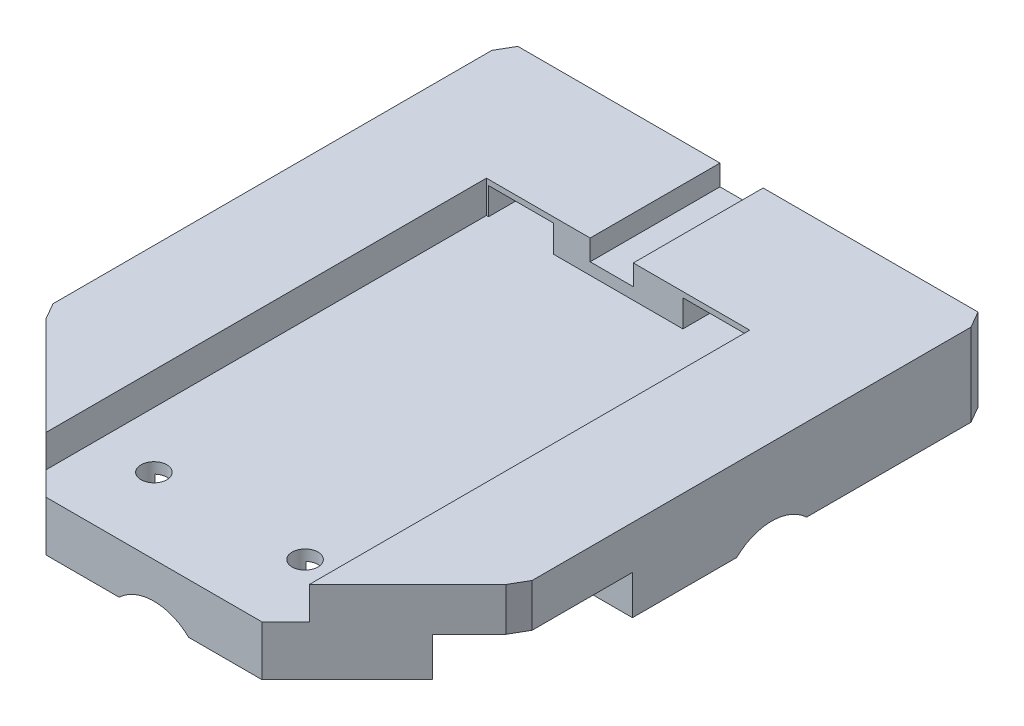
from build123d import *

# Parameters (mm, degrees)
BOSS_EXTRUDE1_DEPTH  = 3.81
SKETCH2_W            = 30.48
SKETCH2_H            = 48.26
CUT_EXTRUDE1_DEPTH   = 3.81
SKETCH4_W            = 30.48
SKETCH4_H            = 3.81
CUT_EXTRUDE2_DEPTH   = 27.94
SKETCH5_W            = 0.25
SKETCH5_H            = 3.81
CUT_EXTRUDE3_DEPTH   = 53.07
CUT_EXTRUDE4_DEPTH   = 7.874
BOSS_EXTRUDE2_DEPTH  = 1.27
SKETCH8_R            = 1.524
CUT_EXTRUDE6_DEPTH   = 6.08
SKETCH9_W            = 5.08
SKETCH9_H            = 5.08
CUT_EXTRUDE7_DEPTH   = 70.883682204
SKETCH10_OUTSIDE_W   = 96.904
SKETCH10_OUTSIDE_H   = 92.332
SKETCH10_OUTSIDE_W_2 = 56.38
SKETCH10_OUTSIDE_H_2 = 76.267364408
CUT_EXTRUDE8_DEPTH   = 6.08
SKETCH11_W           = 26.4
SKETCH11_H           = 2.57
SKETCH11_W_2         = 2.57
SKETCH11_H_2         = 26.4
BOSS_EXTRUDE4_DEPTH  = 4.62
SKETCH12_R           = 5.92
CUT_EXTRUDE9_DEPTH   = 57.38
SKETCH13_R           = 5.92
CUT_EXTRUDE10_DEPTH  = 70.883682204


with BuildPart() as part:
    # Sketch1 → Boss-Extrude1 (new body)
    with BuildSketch(Plane.XZ.offset(12.45)):
        Polygon((-12.7, 31.75), (12.7, 31.75), (27.068409794, 17.381590206), (37.228409794, -0.216045999), (37.228409794, -20.536045999), (27.068409794, -38.133682204), (-27.068409794, -38.133682204), (-37.228409794, -20.536045999), (-37.228409794, -0.216045999), (-27.068409794, 17.381590206), align=None)
    extrude(amount=-BOSS_EXTRUDE1_DEPTH)

    # Sketch2 → Cut-Extrude1 (cut)
    with BuildSketch(Plane.XZ.offset(12.45)):
        with Locations((0, 1.27)):
            Rectangle(SKETCH2_W, SKETCH2_H)
    extrude(amount=-CUT_EXTRUDE1_DEPTH, mode=Mode.SUBTRACT)

    # Sketch4 → Cut-Extrude2 (cut)
    with BuildSketch(Plane(origin=(0, 0, 25.4), x_dir=(-1, 0, 0), z_dir=(0, 0, -1))):
        with Locations((0, -10.545)):
            Rectangle(SKETCH4_W, SKETCH4_H)
    extrude(amount=-CUT_EXTRUDE2_DEPTH, mode=Mode.SUBTRACT)

    # Sketch5 → Cut-Extrude3 (cut, through all)
    with BuildSketch(Plane.XY.offset(-22.86)):
        with Locations((-15.365, -10.545)):
            Rectangle(SKETCH5_W, SKETCH5_H)
        with Locations((15.365, -10.545)):
            Rectangle(SKETCH5_W, SKETCH5_H)
    extrude(amount=CUT_EXTRUDE3_DEPTH, mode=Mode.SUBTRACT)

    # Sketch6 → Cut-Extrude4 (cut)
    with BuildSketch(Plane.XY.offset(-22.86)):
        Polygon((7.62, -12.45), (15.24, -12.45), (15.24, -9.275), (11.557, -9.275), (7.62, -9.275), align=None)
        Polygon((-15.24, -12.45), (-15.24, -9.275), (-11.557, -9.275), (-7.62, -9.275), (-7.62, -12.45), align=None)
    extrude(amount=-CUT_EXTRUDE4_DEPTH, mode=Mode.SUBTRACT)

    # Sketch1_3 → Boss-Extrude2 (add)
    with BuildSketch(Plane.XZ.offset(12.45)):
        Polygon((-12.7, 31.75), (12.7, 31.75), (27.068409794, 17.381590206), (37.228409794, -0.216045999), (37.228409794, -20.536045999), (27.068409794, -38.133682204), (-27.068409794, -38.133682204), (-37.228409794, -20.536045999), (-37.228409794, -0.216045999), (-27.068409794, 17.381590206), align=None)
    extrude(amount=BOSS_EXTRUDE2_DEPTH)

    # Sketch8 → Cut-Extrude6 (cut, through all)
    with BuildSketch(Plane.XZ.offset(13.72)):
        with Locations((-8.89, 22.86)):
            Circle(SKETCH8_R)
        with Locations((8.89, 22.86)):
            Circle(SKETCH8_R)
    extrude(amount=-CUT_EXTRUDE6_DEPTH, mode=Mode.SUBTRACT)

    # Sketch9 → Cut-Extrude7 (cut, through all)
    with BuildSketch(Plane(origin=(0, 0, -38.133682204), x_dir=(-1, 0, 0), z_dir=(0, 0, -1))):
        with Locations((0.7493, -8.5252)):
            Rectangle(SKETCH9_W, SKETCH9_H)
    extrude(amount=-CUT_EXTRUDE7_DEPTH, mode=Mode.SUBTRACT)

    # Sketch10 outside → Cut-Extrude8 (cut, through all)
    with BuildSketch(Plane.XZ.offset(13.72)):
        with Locations((0, -3.192)):
            Rectangle(SKETCH10_OUTSIDE_W, SKETCH10_OUTSIDE_H)
        Rectangle(SKETCH10_OUTSIDE_W_2, SKETCH10_OUTSIDE_H_2, mode=Mode.SUBTRACT)
    extrude(amount=-CUT_EXTRUDE8_DEPTH, mode=Mode.SUBTRACT)

    # Sketch11 → Boss-Extrude4 (add)
    with BuildSketch(Plane.XZ.offset(13.72)):
        with BuildLine():
            Line((22.725, 21.725), (12.7, 31.75))
            Line((12.7, 31.75), (-12.7, 31.75))
            Line((-12.7, 31.75), (-22.725, 21.725))
            Line((-22.725, 21.725), (-9.907030481, 21.725))
            ThreePointArc((-9.907030481, 21.725), (-9.511539036, 24.251497476), (-7.366, 22.86))
            ThreePointArc((-7.366, 22.86), (-7.498502524, 22.238460964), (-7.872969519, 21.725))
            Line((-7.872969519, 21.725), (7.872969519, 21.725))
            ThreePointArc((7.872969519, 21.725), (8.268460964, 24.251497476), (10.414, 22.86))
            ThreePointArc((10.414, 22.86), (10.281497476, 22.238460964), (9.907030481, 21.725))
            Line((9.907030481, 21.725), (22.725, 21.725))
        make_face()
        with Locations((0, 26.185)):
            Rectangle(SKETCH11_W, SKETCH11_H, mode=Mode.SUBTRACT)
        Polygon((-27.068409794, -38.133682204), (-18.165, -38.133682204), (-18.165, 3.641317796), (-28.19, 3.641317796), (-28.19, -36.191030981), align=None)
        with Locations((-22.625, -12.733682204)):
            Rectangle(SKETCH11_W_2, SKETCH11_H_2, mode=Mode.SUBTRACT)
        Polygon((28.19, -36.191030981), (28.19, 3.641317796), (18.165, 3.641317796), (18.165, -38.133682204), (27.068409794, -38.133682204), align=None)
        with Locations((22.625, -12.733682204)):
            Rectangle(SKETCH11_W_2, SKETCH11_H_2, mode=Mode.SUBTRACT)
    extrude(amount=BOSS_EXTRUDE4_DEPTH)

    # Sketch12 → Cut-Extrude9 (cut, through all)
    with BuildSketch(Plane(origin=(28.19, 0, 0), x_dir=(0, 0, -1), z_dir=(1, 0, 0))):
        with Locations((12.735281649, -22.602468851)):
            Circle(SKETCH12_R)
    extrude(amount=-CUT_EXTRUDE9_DEPTH, mode=Mode.SUBTRACT)

    # Sketch13 → Cut-Extrude10 (cut, through all)
    with BuildSketch(Plane.XY.offset(31.75)):
        with Locations((-0.001599445, -22.617531149)):
            Circle(SKETCH13_R)
    extrude(amount=-CUT_EXTRUDE10_DEPTH, mode=Mode.SUBTRACT)


solid = part.part
